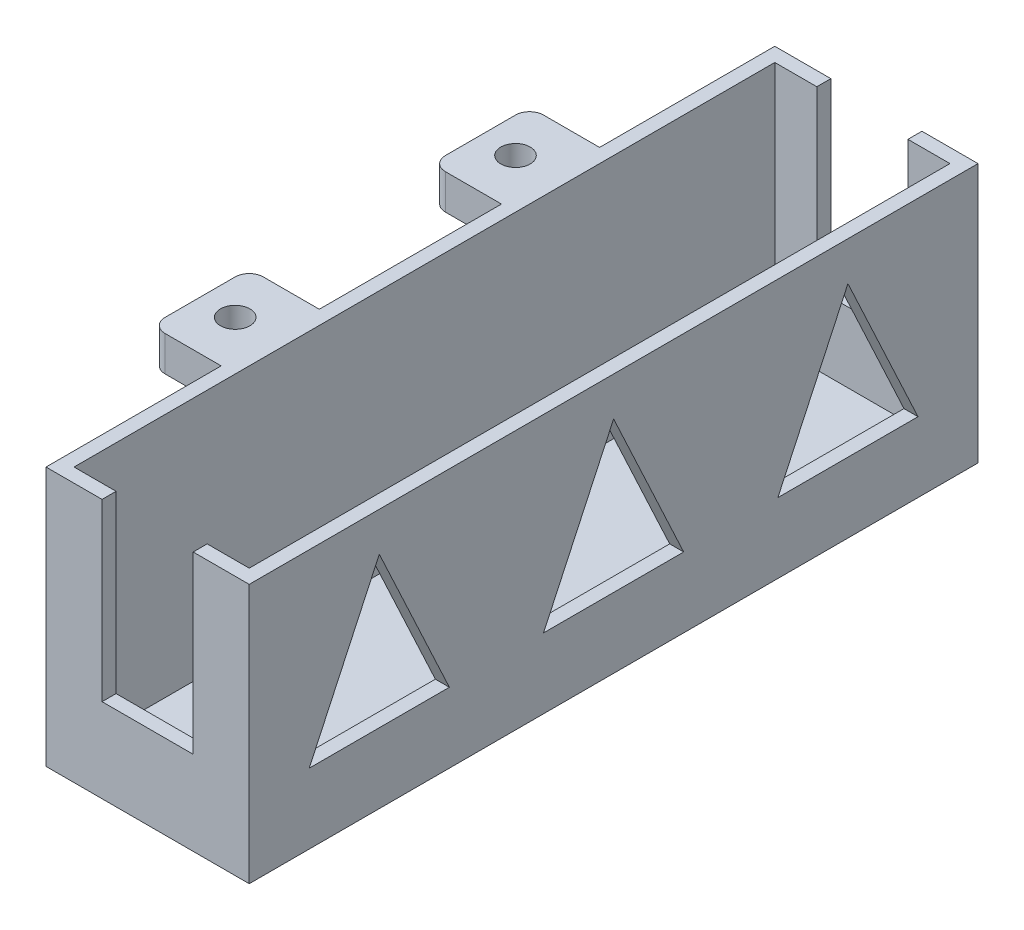
from build123d import *

# Parameters (mm, degrees)
SKETCH2_W             = 10
SKETCH2_H             = 14
SKETCH2_R             = 2.1
BOSS_EXTRUDE1_DEPTH   = 5
BOSS_EXTRUDE1_2_DEPTH = 5
SKETCH3_W             = 44.5
SKETCH3_H             = 39
SKETCH3_W_2           = 14
SKETCH3_H_2           = 5
BOSS_EXTRUDE2_DEPTH   = 2
BOSS_EXTRUDE4_DEPTH   = 32
SKETCH5_W             = 2
SKETCH5_H             = 85
BOSS_EXTRUDE5_DEPTH   = 37
SKETCH6_W             = 14
SKETCH6_H             = 30
CUT_EXTRUDE1_DEPTH    = 200
SKETCH7_W             = 20
SKETCH7_H             = 20
CUT_EXTRUDE2_DEPTH    = 16
FILLET1_R             = 2
SKETCH8_W             = 119.619460544
SKETCH8_H             = 55.607641494
CUT_EXTRUDE3_DEPTH    = 32
SKETCH9_W             = 100
SKETCH9_H             = 35
BOSS_EXTRUDE6_DEPTH   = 2
SKETCH10_W            = 89
SKETCH10_H            = 4
CUT_EXTRUDE4_DEPTH    = 10
BOSS_EXTRUDE7_DEPTH   = 25
SKETCH12_W            = 2
SKETCH12_H            = 35
BOSS_EXTRUDE8_DEPTH   = 2
SKETCH13_W            = 104
SKETCH13_H            = 37
BOSS_EXTRUDE9_DEPTH   = 2
SKETCH14_W            = 13
SKETCH14_H            = 30
CUT_EXTRUDE5_DEPTH    = 104
SKETCH15_W            = 13
SKETCH15_H            = 25
CUT_EXTRUDE7_DEPTH    = 120


with BuildPart() as part:
    # Sketch2 → Boss-Extrude1 (new body)
    with BuildSketch(Plane(origin=(0, 0, 0), x_dir=(1, 0, 0), z_dir=(0, 1, 0))):
        with Locations((114.448385229, -132.360414745)):
            Rectangle(SKETCH2_W, SKETCH2_H)
        with Locations((114.448385229, -132.360414745)):
            Circle(SKETCH2_R, mode=Mode.SUBTRACT)
    extrude(amount=BOSS_EXTRUDE1_DEPTH)



with BuildPart() as body_2:
    # Sketch2 → Boss-Extrude1 2 (new body)
    with BuildSketch(Plane(origin=(0, 0, 0), x_dir=(1, 0, 0), z_dir=(0, 1, 0))):
        with Locations((114.448385229, -172.360414745)):
            Rectangle(SKETCH2_W, SKETCH2_H)
        with Locations((114.448385229, -172.360414745)):
            Circle(SKETCH2_R, mode=Mode.SUBTRACT)
    extrude(amount=BOSS_EXTRUDE1_2_DEPTH)


with BuildPart() as part_1:
    add(part.part)

    add(body_2.part)  # Boss-Extrude2 merges body 2
    # Sketch3 → Boss-Extrude2 (add)
    with BuildSketch(Plane(origin=(119.448385229, 0, 0), x_dir=(0, 0, -1), z_dir=(1, 0, 0))):
        Polygon((-152.360414745, -34), (-152.360414745, 5), (-165.360414745, 5), (-165.360414745, 0), (-179.360414745, 0), (-179.360414745, 5), (-196.860414745, 5), (-196.860414745, -34), align=None)
        with Locations((-130.110414745, -14.5)):
            Rectangle(SKETCH3_W, SKETCH3_H)
        with Locations((-172.360414745, 2.5)):
            Rectangle(SKETCH3_W_2, SKETCH3_H_2)
    extrude(amount=BOSS_EXTRUDE2_DEPTH)

    # Sketch4 → Boss-Extrude4 (add)
    with BuildSketch(Plane(origin=(121.448385229, 0, 0), x_dir=(0, 0, -1), z_dir=(1, 0, 0))):
        Polygon((-194.860414745, 5), (-196.860414745, 5), (-196.860414745, -34), (-107.860414745, -34), (-107.860414745, 5), (-109.860414745, 5), (-109.860414745, -32), (-194.860414745, -32), align=None)
    extrude(amount=BOSS_EXTRUDE4_DEPTH)

    # Sketch5 → Boss-Extrude5 (add)
    with BuildSketch(Plane(origin=(0, -32, 0), x_dir=(1, 0, 0), z_dir=(0, 1, 0))):
        with Locations((152.448385229, -152.360414745)):
            Rectangle(SKETCH5_W, SKETCH5_H)
    extrude(amount=BOSS_EXTRUDE5_DEPTH)

    # Sketch6 → Cut-Extrude1 (cut)
    with BuildSketch(Plane.XY.offset(196.860414745)):
        with Locations((136.448385229, -10)):
            Rectangle(SKETCH6_W, SKETCH6_H)
    extrude(amount=-CUT_EXTRUDE1_DEPTH, mode=Mode.SUBTRACT)

    # Sketch7 → Cut-Extrude2 (cut)
    with BuildSketch(Plane(origin=(153.448385229, 0, 0), x_dir=(0, 0, -1), z_dir=(1, 0, 0))):
        with Locations((-179.360414745, -14.5)):
            Rectangle(SKETCH7_W, SKETCH7_H)
        with Locations((-152.360414745, -14.5)):
            Rectangle(SKETCH7_W, SKETCH7_H)
        with Locations((-125.360414745, -14.5)):
            Rectangle(SKETCH7_W, SKETCH7_H)
    extrude(amount=-CUT_EXTRUDE2_DEPTH, mode=Mode.SUBTRACT)

    # Fillet1
    fillet1_edges = [part_1.edges().sort_by_distance(p)[0] for p in [
        (109.448385229, 2.5, 139.360414745),
        (109.448385229, 2.5, 125.360414745),
        (109.448385229, 2.5, 179.360414745),
        (109.448385229, 2.5, 165.360414745),
    ]]
    fillet(fillet1_edges, radius=FILLET1_R)

    # Sketch8 → Cut-Extrude3 (cut)
    with BuildSketch(Plane(origin=(153.448385229, 0, 0), x_dir=(0, 0, -1), z_dir=(1, 0, 0))):
        with Locations((-148.578534845, -15.335015755)):
            Rectangle(SKETCH8_W, SKETCH8_H)
    extrude(amount=-CUT_EXTRUDE3_DEPTH, mode=Mode.SUBTRACT)

    # Sketch9 → Boss-Extrude6 (add)
    with BuildSketch(Plane(origin=(121.448385229, 0, 0), x_dir=(0, 0, -1), z_dir=(1, 0, 0))):
        with Locations((-152.360414745, -12.5)):
            Rectangle(SKETCH9_W, SKETCH9_H)
    extrude(amount=-BOSS_EXTRUDE6_DEPTH)

    # Sketch10 → Cut-Extrude4 (cut)
    with BuildSketch(Plane(origin=(121.448385229, 0, 0), x_dir=(0, 0, -1), z_dir=(1, 0, 0))):
        with Locations((-152.360414745, -32)):
            Rectangle(SKETCH10_W, SKETCH10_H)
    extrude(amount=-CUT_EXTRUDE4_DEPTH, mode=Mode.SUBTRACT)



with BuildPart() as body_2_2:
    # Sketch11 → Boss-Extrude7 (new body)
    with BuildSketch(Plane(origin=(121.448385229, 0, 0), x_dir=(0, 0, -1), z_dir=(1, 0, 0))):
        Polygon((-202.360414745, -30), (-202.360414745, 5), (-204.360414745, 5), (-204.360414745, -32), (-100.360414745, -32), (-100.360414745, 5), (-102.360414745, 5), (-102.360414745, -30), align=None)
    extrude(amount=BOSS_EXTRUDE7_DEPTH)


with BuildPart() as part_2:
    add(part_1.part)

    add(body_2_2.part)  # Boss-Extrude8 merges body 2 2
    # Sketch12 → Boss-Extrude8 (add)
    with BuildSketch(Plane.ZY.offset(-121.448385229)):
        with Locations((101.360414745, -12.5)):
            Rectangle(SKETCH12_W, SKETCH12_H)
        Polygon((102.360414745, -30), (100.360414745, -30), (100.360414745, -32), (204.360414745, -32), (204.360414745, -30), (202.360414745, -30), align=None)
        with Locations((203.360414745, -12.5)):
            Rectangle(SKETCH12_W, SKETCH12_H)
    extrude(amount=BOSS_EXTRUDE8_DEPTH)

    # Sketch13 → Boss-Extrude9 (add)
    with BuildSketch(Plane(origin=(146.448385229, 0, 0), x_dir=(0, 0, -1), z_dir=(1, 0, 0))):
        with Locations((-152.360414745, -13.5)):
            Rectangle(SKETCH13_W, SKETCH13_H)
        Polygon((-195.798080738, -22), (-175.798080738, -22), (-185.798080738, -0.554930795), align=None, mode=Mode.SUBTRACT)
        Polygon((-128.922748753, -22), (-118.922748753, -0.554930795), (-108.922748753, -22), align=None, mode=Mode.SUBTRACT)
        Polygon((-162.360414745, -22), (-142.360414745, -22), (-152.360414745, -0.554930795), align=None, mode=Mode.SUBTRACT)
    extrude(amount=BOSS_EXTRUDE9_DEPTH)

    # Sketch14 → Cut-Extrude5 (cut)
    with BuildSketch(Plane(origin=(0, 0, 100.360414745), x_dir=(-1, 0, 0), z_dir=(0, 0, -1))):
        with Locations((-133.948385229, 5)):
            Rectangle(SKETCH14_W, SKETCH14_H)
    extrude(amount=-CUT_EXTRUDE5_DEPTH, mode=Mode.SUBTRACT)

    # Sketch15 → Cut-Extrude7 (cut)
    with BuildSketch(Plane(origin=(0, 0, 100.360414745), x_dir=(-1, 0, 0), z_dir=(0, 0, -1))):
        with Locations((-133.948385229, -7.5)):
            Rectangle(SKETCH15_W, SKETCH15_H)
    extrude(amount=-CUT_EXTRUDE7_DEPTH, mode=Mode.SUBTRACT)


solid = part_2.part
